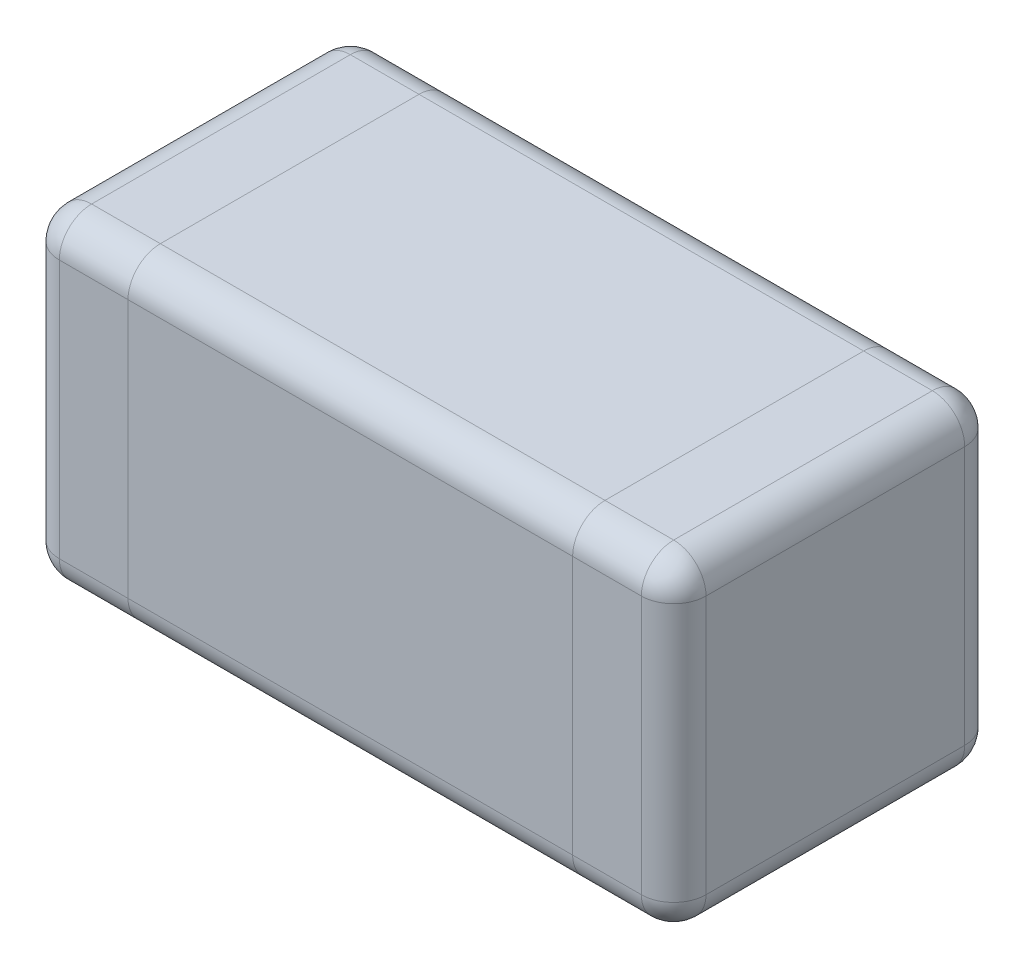
from build123d import *

# Parameters (mm, degrees)
ESBO_O1_W                = 1.6
ESBO_O1_H                = 0.8
RESSALTO_EXTRUS_O1_DEPTH = 0.8
FILETE2_R                = 0.08


with BuildPart() as part:
    # Esboço1 → Ressalto-extrusão1 (new body)
    with BuildSketch(Plane(origin=(0, 0, 0), x_dir=(1, 0, 0), z_dir=(0, 1, 0))):
        with Locations((0.8, 0.4)):
            Rectangle(ESBO_O1_W, ESBO_O1_H)
    extrude(amount=RESSALTO_EXTRUS_O1_DEPTH)

    # Filete2
    filete2_edges = [part.edges().sort_by_distance(p)[0] for p in [
        (1.6, 0.8, -0.4),
        (0.8, 0.8, -0.8),
        (0, 0.8, -0.4),
        (0.8, 0, -0.8),
        (1.6, 0, -0.4),
        (0.8, 0, 0),
        (0, 0, -0.4),
        (0.8, 0.8, 0),
        (0, 0.4, -0.8),
        (1.6, 0.4, -0.8),
        (1.6, 0.4, 0),
        (0, 0.4, 0),
    ]]
    fillet(filete2_edges, radius=FILETE2_R)


solid = part.part
